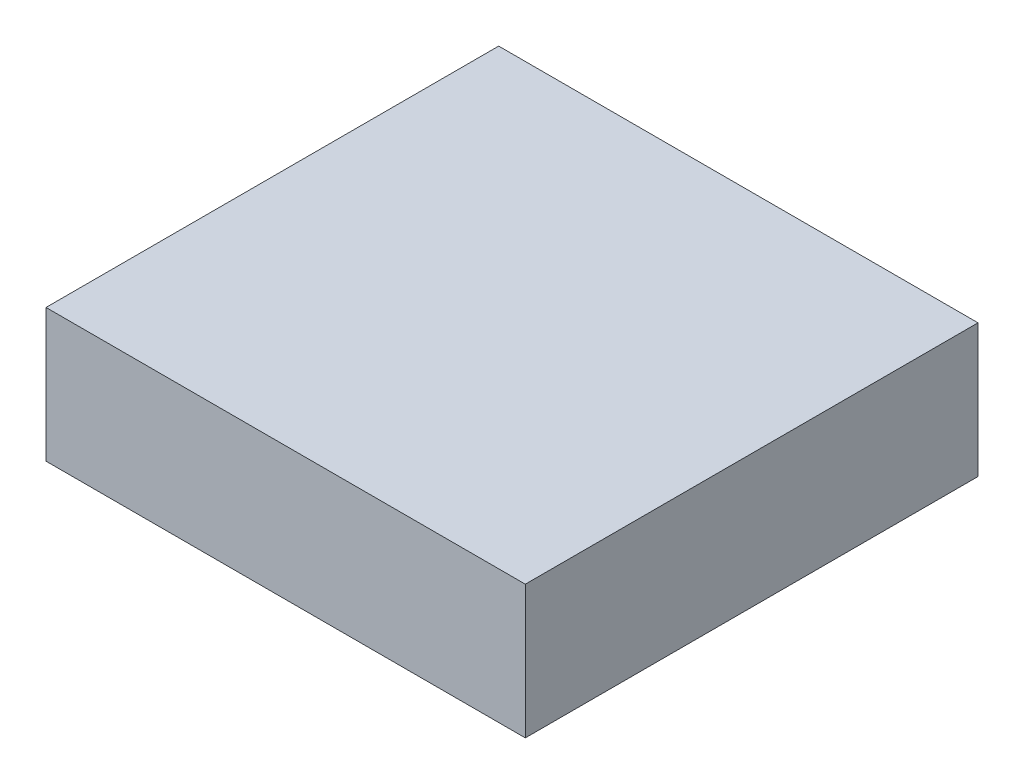
from build123d import *

# Parameters (mm, degrees)
ESBO_O1_W                = 85
ESBO_O1_H                = 25
RESSALTO_EXTRUS_O1_DEPTH = 90


with BuildPart() as part:
    # Esboço1 → Ressalto-extrusão1 (new body)
    with BuildSketch(Plane(origin=(0, 0, 0), x_dir=(0, 0, -1), z_dir=(1, 0, 0))):
        Rectangle(ESBO_O1_W, ESBO_O1_H)
    extrude(amount=RESSALTO_EXTRUS_O1_DEPTH)


solid = part.part
